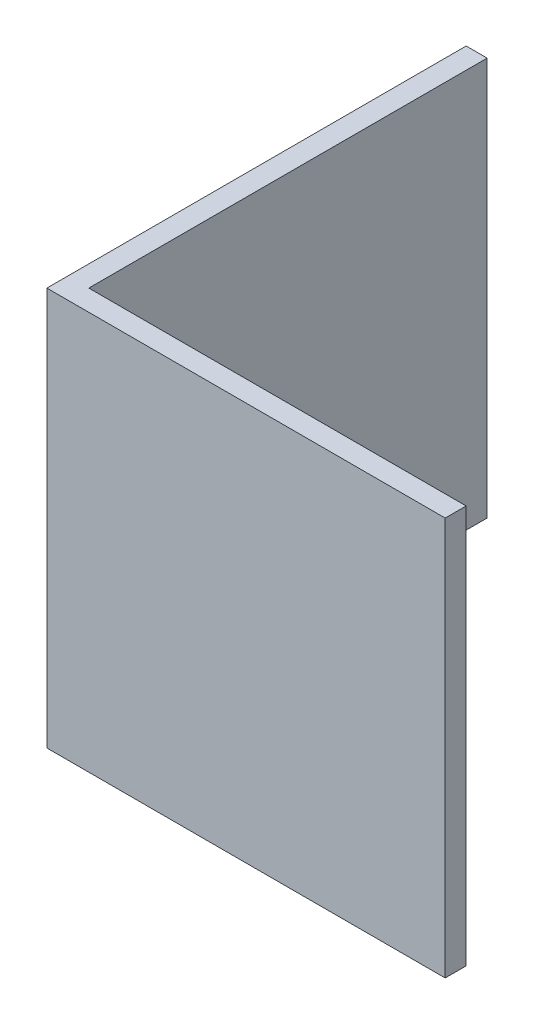
from build123d import *

# Parameters (mm, degrees)
EXTRUDE_1_DEPTH     = 19
SKETCH_2_W          = 1
SKETCH_2_H          = 19
CUT_EXTRUDE_1_DEPTH = 1


with BuildPart() as part:
    # Эскиз1 → Бобышка-Вытянуть1 (new body)
    with BuildSketch(Plane(origin=(0, 0, 0), x_dir=(1, 0, 0), z_dir=(0, 1, 0))):
        Polygon((0, 0), (0, 20), (1, 20), (1, 1), (20, 1), (20, 0), align=None)
    extrude(amount=EXTRUDE_1_DEPTH)

    # Эскиз2 → Вырез-Вытянуть1 (cut)
    with BuildSketch(Plane(origin=(20, 0, 0), x_dir=(0, 0, -1), z_dir=(1, 0, 0))):
        with Locations((0.5, 9.5)):
            Rectangle(SKETCH_2_W, SKETCH_2_H)
    extrude(amount=-CUT_EXTRUDE_1_DEPTH, mode=Mode.SUBTRACT)


solid = part.part
